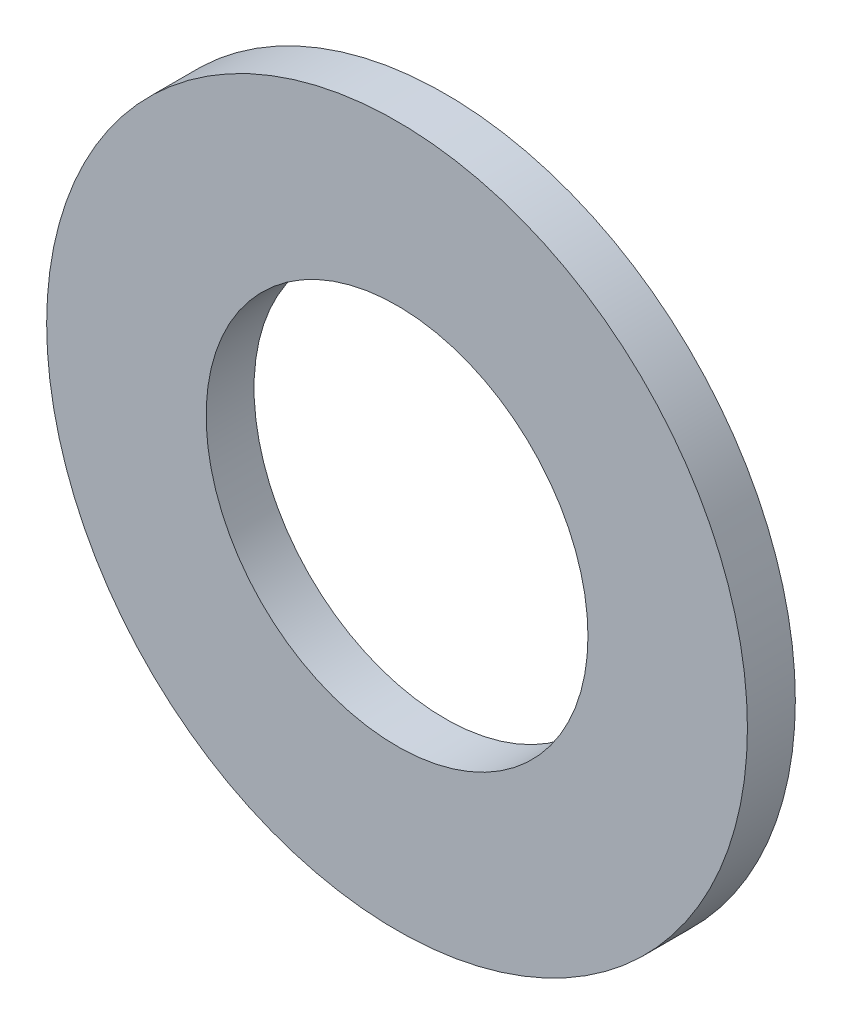
from build123d import *

# Parameters (mm, degrees)
SKETCH3_R           = 5.9436
SKETCH3_R_2         = 3.2385
BOSS_EXTRUDE1_DEPTH = 0.4064


with BuildPart() as part:
    # Sketch3 → Boss-Extrude1 (new, symmetric)
    with BuildSketch(Plane.XY):
        Circle(SKETCH3_R)
        Circle(SKETCH3_R_2, mode=Mode.SUBTRACT)
    extrude(amount=BOSS_EXTRUDE1_DEPTH, both=True)


solid = part.part
